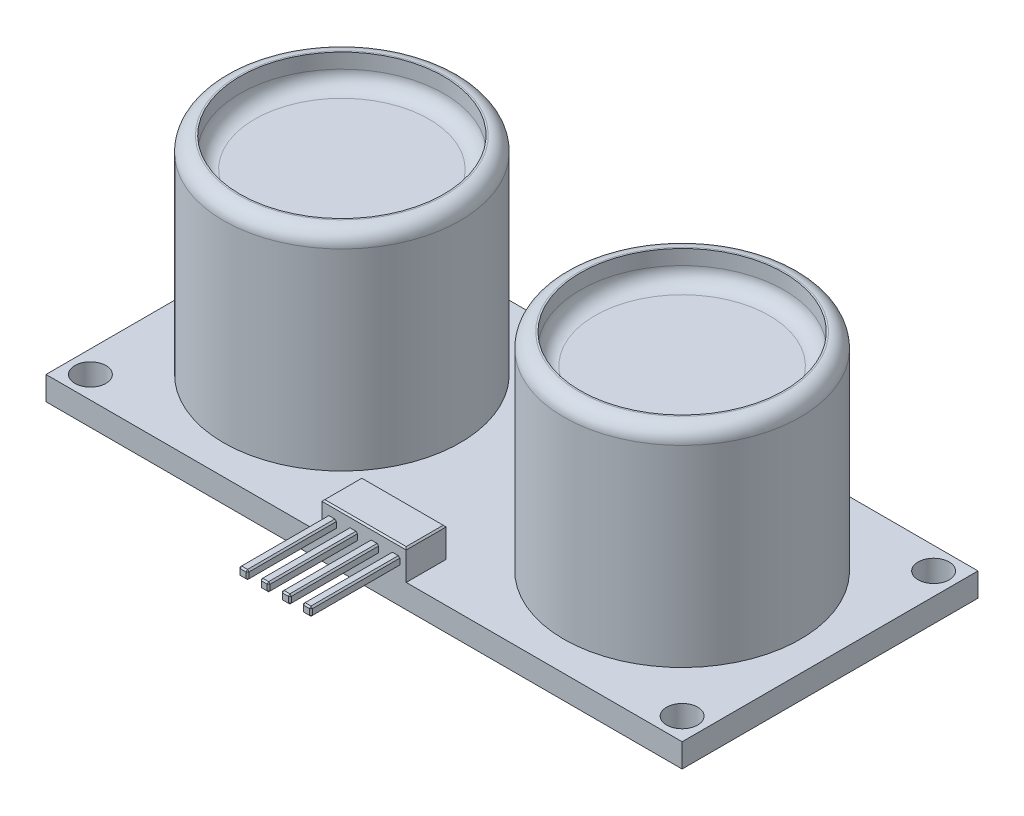
from build123d import *

# Parameters (mm, degrees)
SKETCH1_W            = 43
SKETCH1_H            = 20
BOSS_EXTRUDE1_DEPTH  = 1.6
SKETCH2_R            = 8
BOSS_EXTRUDE2_DEPTH  = 14
SKETCH3_R            = 6.893962295
CUT_EXTRUDE1_DEPTH   = 2
FILLET1_R            = 1
FILLET2_R            = 1
FILLET1_OF_MIRROR1_R = 1
FILLET2_OF_MIRROR1_R = 1
BOSS_EXTRUDE3_DEPTH  = 2
SKETCH5_W            = 0.6
SKETCH5_H            = 0.6
BOSS_EXTRUDE4_DEPTH  = 6
CHAMFER1_SIZE        = 0.1
CHAMFER2_SIZE        = 0.1
CUT_EXTRUDE2_REACH   = 51.447
SKETCH6_R            = 1.05


with BuildPart() as part:
    # Sketch1 → Boss-Extrude1 (new body)
    with BuildSketch(Plane(origin=(0, 0, 0), x_dir=(1, 0, 0), z_dir=(0, 1, 0))):
        with Locations((21.5, 10)):
            Rectangle(SKETCH1_W, SKETCH1_H)
    extrude(amount=BOSS_EXTRUDE1_DEPTH)

    # Sketch2 → Boss-Extrude2 (add)
    with BuildSketch(Plane(origin=(0, 1.6, 0), x_dir=(1, 0, 0), z_dir=(0, 1, 0))):
        with Locations((10, 10)):
            Circle(SKETCH2_R)
    boss_extrude2 = extrude(amount=BOSS_EXTRUDE2_DEPTH)

    # Sketch3 → Cut-Extrude1 (cut)
    with BuildSketch(Plane(origin=(0, 15.6, 0), x_dir=(1, 0, 0), z_dir=(0, 1, 0))):
        with Locations((10, 10)):
            Circle(SKETCH3_R)
    cut_extrude1 = extrude(amount=-CUT_EXTRUDE1_DEPTH, mode=Mode.SUBTRACT)

    # Fillet1
    fillet1_edges = [part.edges().sort_by_distance(p)[0] for p in [
        (2, 15.6, -10),
    ]]
    fillet(fillet1_edges, radius=FILLET1_R)

    # Fillet2
    fillet2_edges = [part.edges().sort_by_distance(p)[0] for p in [
        (3.106037705, 13.6, -10),
    ]]
    fillet(fillet2_edges, radius=FILLET2_R)

    # Mirror1: Boss-Extrude2, Cut-Extrude1 across plane
    add(boss_extrude2.mirror(Plane(origin=(21.5, 0, 0), x_dir=(0, 0, 1), z_dir=(1, 0, 0))))
    add(cut_extrude1.mirror(Plane(origin=(21.5, 0, 0), x_dir=(0, 0, 1), z_dir=(1, 0, 0))), mode=Mode.SUBTRACT)

    # Fillet1 of Mirror1
    fillet1_of_mirror1_edges = [part.edges().sort_by_distance(p)[0] for p in [
        (41, 15.6, -10),
    ]]
    fillet(fillet1_of_mirror1_edges, radius=FILLET1_OF_MIRROR1_R)

    # Fillet2 of Mirror1
    fillet2_of_mirror1_edges = [part.edges().sort_by_distance(p)[0] for p in [
        (39.893962295, 13.6, -10),
    ]]
    fillet(fillet2_of_mirror1_edges, radius=FILLET2_OF_MIRROR1_R)

    # Sketch4 → Boss-Extrude3 (add)
    with BuildSketch(Plane(origin=(0, 1.6, 0), x_dir=(1, 0, 0), z_dir=(0, 1, 0))):
        Polygon((21.5, 0), (18.65, 0), (18.65, 2.7), (24.35, 2.7), (24.35, 0), align=None)
    extrude(amount=BOSS_EXTRUDE3_DEPTH)

    # Sketch5 → Boss-Extrude4 (add)
    with BuildSketch(Plane.XY):
        with Locations((19.322458837, 2.6)):
            Rectangle(SKETCH5_W, SKETCH5_H)
        with Locations((20.752458837, 2.6)):
            Rectangle(SKETCH5_W, SKETCH5_H)
        with Locations((22.182458837, 2.6)):
            Rectangle(SKETCH5_W, SKETCH5_H)
        with Locations((23.612458837, 2.6)):
            Rectangle(SKETCH5_W, SKETCH5_H)
    extrude(amount=BOSS_EXTRUDE4_DEPTH)

    # Chamfer1
    chamfer1_edges = [part.edges().sort_by_distance(p)[0] for p in [
        (23.912458837, 2.6, 6),
        (23.912458837, 2.3, 3),
        (23.612458837, 2.3, 6),
        (23.312458837, 2.3, 3),
        (23.312458837, 2.6, 6),
        (23.912458837, 2.9, 3),
        (23.612458837, 2.9, 6),
        (23.312458837, 2.9, 3),
        (22.482458837, 2.6, 6),
        (22.482458837, 2.3, 3),
        (22.182458837, 2.3, 6),
        (21.882458837, 2.3, 3),
        (21.882458837, 2.6, 6),
        (21.882458837, 2.9, 3),
        (22.182458837, 2.9, 6),
        (22.482458837, 2.9, 3),
        (21.052458837, 2.6, 6),
        (21.052458837, 2.3, 3),
        (20.752458837, 2.3, 6),
        (20.452458837, 2.3, 3),
        (20.452458837, 2.6, 6),
        (21.052458837, 2.9, 3),
        (20.752458837, 2.9, 6),
        (20.452458837, 2.9, 3),
        (19.322458837, 2.3, 6),
        (19.022458837, 2.3, 3),
        (19.022458837, 2.6, 6),
        (19.022458837, 2.9, 3),
        (19.322458837, 2.9, 6),
        (19.622458837, 2.3, 3),
        (19.622458837, 2.6, 6),
        (19.622458837, 2.9, 3),
    ]]
    chamfer(chamfer1_edges, length=CHAMFER1_SIZE)

    # Chamfer2
    chamfer2_edges = [part.edges().sort_by_distance(p)[0] for p in [
        (18.65, 3.6, -1.35),
        (21.5, 3.6, -2.7),
        (24.35, 3.6, -1.35),
        (21.5, 3.6, 0),
    ]]
    chamfer(chamfer2_edges, length=CHAMFER2_SIZE)

    # Sketch6 → Cut-Extrude2 (cut, up to next)
    with BuildSketch(Plane(origin=(0, 1.6, 0), x_dir=(1, 0, 0), z_dir=(0, 1, 0)), mode=Mode.PRIVATE) as cut_extrude2_sk1:
        with Locations((1.5, 18.5)):
            Circle(SKETCH6_R)
    cut_extrude2_tool1 = extrude(cut_extrude2_sk1.sketch, amount=-CUT_EXTRUDE2_REACH, mode=Mode.PRIVATE) & part.part
    # Sketch6 → Cut-Extrude2 (cut, up to next)
    with BuildSketch(Plane(origin=(0, 1.6, 0), x_dir=(1, 0, 0), z_dir=(0, 1, 0)), mode=Mode.PRIVATE) as cut_extrude2_sk2:
        with Locations((1.5, 1.5)):
            Circle(SKETCH6_R)
    cut_extrude2_tool2 = extrude(cut_extrude2_sk2.sketch, amount=-CUT_EXTRUDE2_REACH, mode=Mode.PRIVATE) & part.part
    # Sketch6 → Cut-Extrude2 (cut, up to next)
    with BuildSketch(Plane(origin=(0, 1.6, 0), x_dir=(1, 0, 0), z_dir=(0, 1, 0)), mode=Mode.PRIVATE) as cut_extrude2_sk3:
        with Locations((41.5, 1.5)):
            Circle(SKETCH6_R)
    cut_extrude2_tool3 = extrude(cut_extrude2_sk3.sketch, amount=-CUT_EXTRUDE2_REACH, mode=Mode.PRIVATE) & part.part
    # Sketch6 → Cut-Extrude2 (cut, up to next)
    with BuildSketch(Plane(origin=(0, 1.6, 0), x_dir=(1, 0, 0), z_dir=(0, 1, 0)), mode=Mode.PRIVATE) as cut_extrude2_sk4:
        with Locations((41.5, 18.5)):
            Circle(SKETCH6_R)
    cut_extrude2_tool4 = extrude(cut_extrude2_sk4.sketch, amount=-CUT_EXTRUDE2_REACH, mode=Mode.PRIVATE) & part.part
    add(cut_extrude2_tool1.solids().sort_by_distance((1.5, 1.6, -18.5))[0], mode=Mode.SUBTRACT)
    add(cut_extrude2_tool2.solids().sort_by_distance((1.5, 1.6, -1.5))[0], mode=Mode.SUBTRACT)
    add(cut_extrude2_tool3.solids().sort_by_distance((41.5, 1.6, -1.5))[0], mode=Mode.SUBTRACT)
    add(cut_extrude2_tool4.solids().sort_by_distance((41.5, 1.6, -18.5))[0], mode=Mode.SUBTRACT)


solid = part.part
